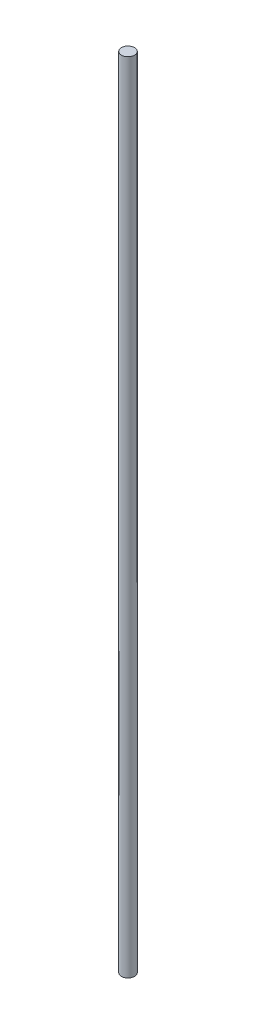
from build123d import *

# Parameters (mm, degrees)
SKETCH_1_R      = 5
EXTRUDE_1_DEPTH = 608


with BuildPart() as part:
    # Эскиз1 → Бобышка-Вытянуть1 (new body)
    with BuildSketch(Plane(origin=(0, 0, 0), x_dir=(1, 0, 0), z_dir=(0, 1, 0))):
        Circle(SKETCH_1_R)
    extrude(amount=EXTRUDE_1_DEPTH)


solid = part.part
